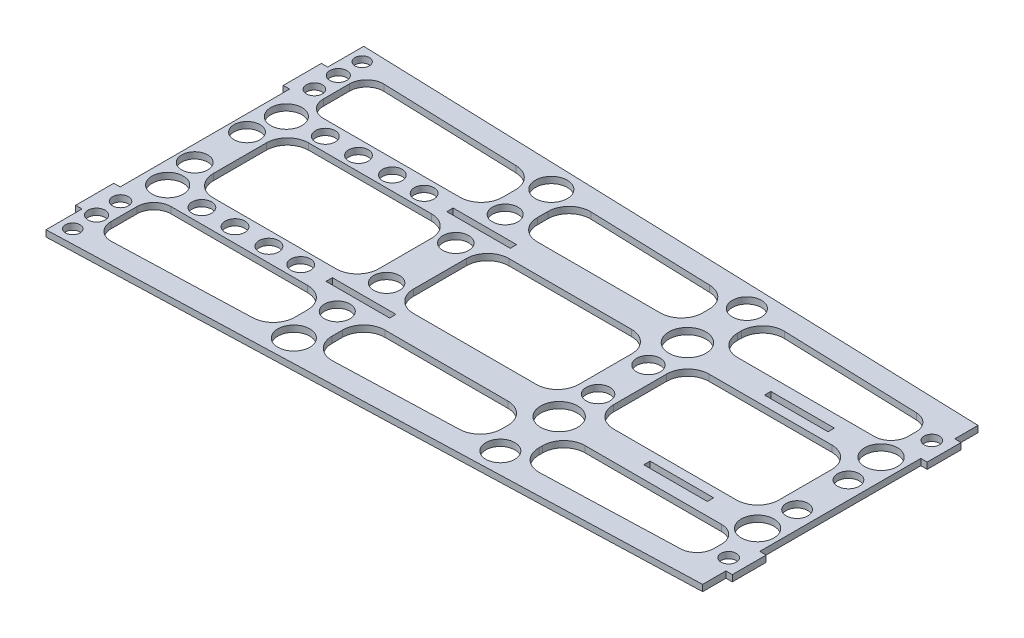
from build123d import *

# Parameters (mm, degrees)
BOSS_EXTRUDE1_DEPTH = 3
SKETCH2_W           = 78
SKETCH2_H           = 45
CUT_EXTRUDE1_DEPTH  = 10
FILLET1_R           = 10
CUT_EXTRUDE2_DEPTH  = 10
SKETCH4_W           = 16.5
SKETCH4_H           = 134.835477832
SKETCH4_H_2         = 126.10677569
BOSS_EXTRUDE2_DEPTH = 3
FILLET2_R           = 10
FILLET3_R           = 10
SKETCH5_W           = 3
SKETCH5_H           = 16
SKETCH5_H_2         = 18
BOSS_EXTRUDE3_DEPTH = 3
SKETCH6_W           = 30
SKETCH6_H           = 3
CUT_EXTRUDE3_DEPTH  = 10
SKETCH7_R           = 7.375435698
SKETCH7_R_2         = 6.026342639
SKETCH7_R_3         = 7.536169895
SKETCH7_R_4         = 8.748796797
SKETCH7_R_5         = 6.84792013
SKETCH7_R_6         = 3.415074188
SKETCH7_R_7         = 4.035175634
SKETCH7_R_8         = 3.768084948
SKETCH7_R_9         = 6.152551264
SKETCH7_R_10        = 4.647289197
SKETCH7_R_11        = 6.093281567
SKETCH7_R_12        = 5.579409228
SKETCH7_R_13        = 7.734472057
SKETCH7_R_14        = 5.13672287
SKETCH7_R_15        = 3.6120817
CUT_EXTRUDE4_DEPTH  = 10


with BuildPart() as part:
    # Sketch1 → Boss-Extrude1 (new body)
    with BuildSketch(Plane(origin=(0, 0, 0), x_dir=(1, 0, 0), z_dir=(0, 1, 0))):
        Polygon((0, 0), (0, 75.000000004), (300, 65), (300, 0), align=None)
    boss_extrude1 = extrude(amount=BOSS_EXTRUDE1_DEPTH)

    # Mirror1: Boss-Extrude1 across Front Plane
    add(boss_extrude1.mirror(Plane.XY))

    # Sketch2 → Cut-Extrude1 (cut)
    with BuildSketch(Plane(origin=(0, 3, 0), x_dir=(1, 0, 0), z_dir=(0, 1, 0))):
        with Locations((55.5, 0)):
            Rectangle(SKETCH2_W, SKETCH2_H)
        with Locations((150, 0)):
            Rectangle(SKETCH2_W, SKETCH2_H)
        with Locations((244.5, 0)):
            Rectangle(SKETCH2_W, SKETCH2_H)
    extrude(amount=-CUT_EXTRUDE1_DEPTH, mode=Mode.SUBTRACT)

    # Fillet1
    fillet1_edges = [part.edges().sort_by_distance(p)[0] for p in [
        (16.5, 1.5, 22.5),
        (16.5, 1.5, -22.5),
        (94.5, 1.5, -22.5),
        (94.5, 1.5, 22.5),
        (111, 1.5, 22.5),
        (111, 1.5, -22.5),
        (189, 1.5, -22.5),
        (189, 1.5, 22.5),
        (205.5, 1.5, 22.5),
        (205.5, 1.5, -22.5),
        (283.5, 1.5, -22.5),
        (283.5, 1.5, 22.5),
    ]]
    fillet(fillet1_edges, radius=FILLET1_R)

    # Sketch3 → Cut-Extrude2 (cut)
    with BuildSketch(Plane(origin=(0, 3, 0), x_dir=(1, 0, 0), z_dir=(0, 1, 0))):
        with BuildLine():
            Line((12, 56.323336113), (12, 44))
            ThreePointArc((12, 44), (14.343145751, 38.343145751), (20, 36))
            Line((20, 36), (280, 36))
            ThreePointArc((280, 36), (285.656854249, 38.343145751), (288, 44))
            Line((288, 44), (288, 47.656669443))
            ThreePointArc((288, 47.656669443), (285.750310824, 53.218496969), (280.266518642, 55.652228699))
            Line((280.266518642, 55.652228699), (20.266518642, 64.318895369))
            ThreePointArc((20.266518642, 64.318895369), (14.438172474, 62.073646937), (12, 56.323336113))
        make_face()
    cut_extrude2 = extrude(amount=-CUT_EXTRUDE2_DEPTH, mode=Mode.SUBTRACT)

    # Mirror2: Cut-Extrude2 across plane
    add(cut_extrude2.mirror(Plane.XY), mode=Mode.SUBTRACT)

    # Sketch4 → Boss-Extrude2 (add)
    with BuildSketch(Plane(origin=(0, 3, 0), x_dir=(1, 0, 0), z_dir=(0, 1, 0))):
        with Locations((102.75, 0)):
            Rectangle(SKETCH4_W, SKETCH4_H)
        with Locations((197.25, 0)):
            Rectangle(SKETCH4_W, SKETCH4_H_2)
    extrude(amount=-BOSS_EXTRUDE2_DEPTH)

    # Fillet2
    fillet2_edges = [part.edges().sort_by_distance(p)[0] for p in [
        (111, 1.5, -36),
        (111, 1.5, -61.294445989),
        (94.5, 1.5, -36),
        (94.5, 1.5, -61.844445989),
        (189, 1.5, -36),
        (205.5, 1.5, -36),
        (205.5, 1.5, -58.144445988),
        (189, 1.5, -58.694445988),
    ]]
    fillet(fillet2_edges, radius=FILLET2_R)

    # Fillet3
    fillet3_edges = [part.edges().sort_by_distance(p)[0] for p in [
        (94.5, 1.5, 36),
        (111, 1.5, 36),
        (111, 1.5, 61.294445989),
        (94.5, 1.5, 61.844445989),
        (189, 1.5, 58.694445988),
        (189, 1.5, 36),
        (205.5, 1.5, 58.144445988),
        (205.5, 1.5, 36),
    ]]
    fillet(fillet3_edges, radius=FILLET3_R)

    # Sketch5 → Boss-Extrude3 (add)
    with BuildSketch(Plane(origin=(0, 3, 0), x_dir=(1, 0, 0), z_dir=(0, 1, 0))):
        with Locations((301.5, 46)):
            Rectangle(SKETCH5_W, SKETCH5_H)
        with Locations((-1.5, 49)):
            Rectangle(SKETCH5_W, SKETCH5_H_2)
        with Locations((301.5, -46)):
            Rectangle(SKETCH5_W, SKETCH5_H)
        with Locations((-1.5, -49)):
            Rectangle(SKETCH5_W, SKETCH5_H_2)
    extrude(amount=-BOSS_EXTRUDE3_DEPTH)

    # Sketch6 → Cut-Extrude3 (cut)
    with BuildSketch(Plane(origin=(0, 3, 0), x_dir=(1, 0, 0), z_dir=(0, 1, 0))):
        with Locations((102.2, 28.5)):
            Rectangle(SKETCH6_W, SKETCH6_H)
        with Locations((252.2, 28.5)):
            Rectangle(SKETCH6_W, SKETCH6_H)
        with Locations((252.2, -28.5)):
            Rectangle(SKETCH6_W, SKETCH6_H)
        with Locations((102.2, -28.5)):
            Rectangle(SKETCH6_W, SKETCH6_H)
    extrude(amount=-CUT_EXTRUDE3_DEPTH, mode=Mode.SUBTRACT)

    # Sketch7 → Cut-Extrude4 (cut)
    with BuildSketch(Plane(origin=(0, 3, 0), x_dir=(1, 0, 0), z_dir=(0, 1, 0))):
        with Locations((10.460573095, 28.013938864)):
            Circle(SKETCH7_R)
        with Locations((102.139763505, 39.635244691)):
            Circle(SKETCH7_R_2)
        with Locations((102.785391607, 60.779565014)):
            Circle(SKETCH7_R_3)
        with Locations((197.531315499, 30.273637219)):
            Circle(SKETCH7_R_4)
        with Locations((197.692722525, 58.197052608)):
            Circle(SKETCH7_R_5)
        with Locations((5.941176384, 68.31573491)):
            Circle(SKETCH7_R_6)
        with Locations((5.941176384, 57.067203431)):
            Circle(SKETCH7_R_7)
        with Locations((5.941176384, 45.768711655)):
            Circle(SKETCH7_R_8)
        with Locations((7.555246638, 12.357457403)):
            Circle(SKETCH7_R_9)
        with Locations((27.731124809, 29.143788042)):
            Circle(SKETCH7_R_10)
        with Locations((43.38760627, 29.143788042)):
            Circle(SKETCH7_R_10)
        with Locations((59.366901782, 29.143788042)):
            Circle(SKETCH7_R_10)
        with Locations((74.377755141, 29.143788042)):
            Circle(SKETCH7_R_10)
        with Locations((102.139763505, 16.325855723)):
            Circle(SKETCH7_R_11)
        with Locations((197.531315499, 11.888841158)):
            Circle(SKETCH7_R_12)
        with Locations((290.098134793, 29.143788042)):
            Circle(SKETCH7_R_13)
        with Locations((291.718609677, 12.12033757)):
            Circle(SKETCH7_R_14)
        with Locations((295.234857663, 47.963698705)):
            Circle(SKETCH7_R_15)
        with Locations((295.234857663, -47.963698705)):
            Circle(SKETCH7_R_15)
        with Locations((291.718609677, -12.12033757)):
            Circle(SKETCH7_R_14)
        with Locations((290.098134793, -29.143788042)):
            Circle(SKETCH7_R_13)
        with Locations((197.531315499, -11.888841158)):
            Circle(SKETCH7_R_12)
        with Locations((102.139763505, -16.325855723)):
            Circle(SKETCH7_R_11)
        with Locations((74.377755141, -29.143788042)):
            Circle(SKETCH7_R_10)
        with Locations((59.366901782, -29.143788042)):
            Circle(SKETCH7_R_10)
        with Locations((43.38760627, -29.143788042)):
            Circle(SKETCH7_R_10)
        with Locations((27.731124809, -29.143788042)):
            Circle(SKETCH7_R_10)
        with Locations((7.555246638, -12.357457403)):
            Circle(SKETCH7_R_9)
        with Locations((5.941176384, -45.768711655)):
            Circle(SKETCH7_R_8)
        with Locations((5.941176384, -57.067203431)):
            Circle(SKETCH7_R_7)
        with Locations((5.941176384, -68.31573491)):
            Circle(SKETCH7_R_6)
        with Locations((197.692722525, -58.197052608)):
            Circle(SKETCH7_R_5)
        with Locations((197.531315499, -30.273637219)):
            Circle(SKETCH7_R_4)
        with Locations((102.785391607, -60.779565014)):
            Circle(SKETCH7_R_3)
        with Locations((102.139763505, -39.635244691)):
            Circle(SKETCH7_R_2)
        with Locations((10.460573095, -28.013938864)):
            Circle(SKETCH7_R)
    extrude(amount=-CUT_EXTRUDE4_DEPTH, mode=Mode.SUBTRACT)


solid = part.part
